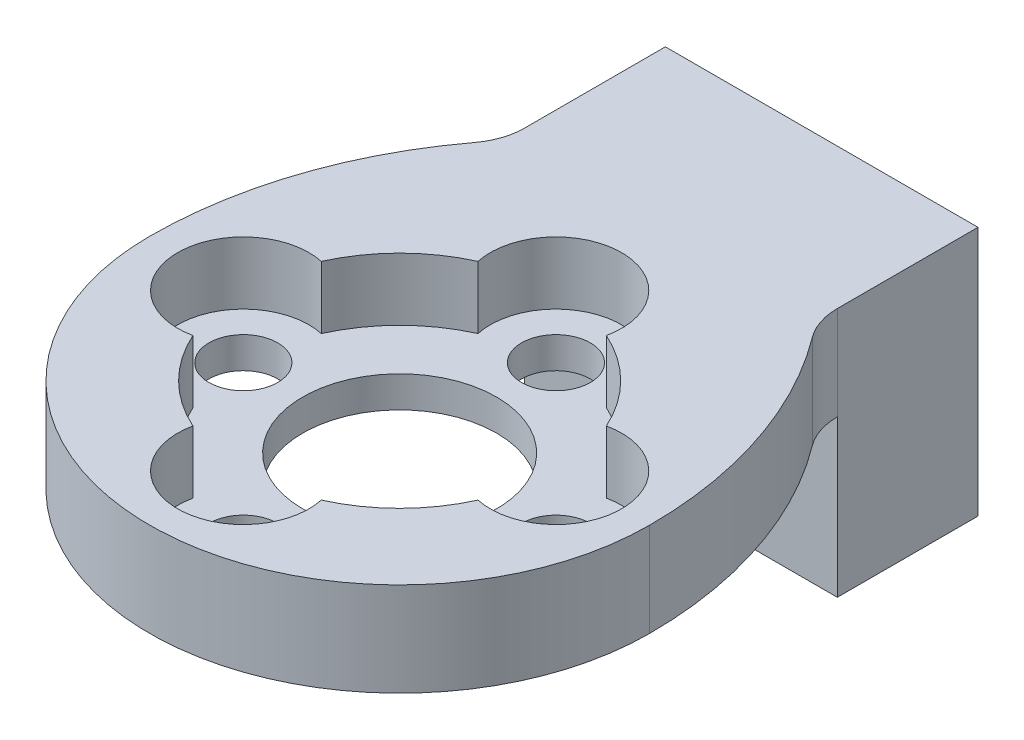
from build123d import *

# Parameters (mm, degrees)
BOSS_EXTRUDE1_DEPTH            = 3
SKETCH2_W                      = 10
SKETCH2_H                      = 4.5
BOSS_EXTRUDE2_DEPTH            = 5
CUT_EXTRUDE1_DEPTH             = 2
F_2_2_2_2_DIAMETER_HOLE1_D     = 2.2
F_2_2_2_2_DIAMETER_HOLE1_DEPTH = 6.000025
F_6_2_6_2_DIAMETER_HOLE1_D     = 6.2
F_6_2_6_2_DIAMETER_HOLE1_DEPTH = 3
F_2_2_2_2_DIAMETER_HOLE2_D     = 2.2
F_2_2_2_2_DIAMETER_HOLE2_DEPTH = 3
F_2_5_2_5_DIAMETER_HOLE1_D     = 2.5
F_2_5_2_5_DIAMETER_HOLE1_DEPTH = 21.5
F_1_6_1_6_DIAMETER_HOLE1_D     = 1.6
F_1_6_1_6_DIAMETER_HOLE1_DEPTH = 4
F_1_6_1_6_DIAMETER_HOLE1_TIP   = 0.480688495
FILLET1_R                      = 2


with BuildPart() as part:
    # Sketch1 → Boss-Extrude1 (new body)
    with BuildSketch(Plane(origin=(0, 3, 0), x_dir=(1, 0, 0), z_dir=(0, 1, 0))):
        with BuildLine():
            Line((5.000000003, -5.193376137), (5.000000003, 0))
            Line((5.000000003, 0), (-4.999999997, 0))
            Line((-4.999999997, 0), (-4.999999997, -5.193376137))
            ThreePointArc((-4.999999997, -5.193376137), (-7.227019257, -9.084119567), (-7.999999997, -13.5))
            ThreePointArc((-7.999999997, -13.5), (3e-09, -21.5), (8.000000003, -13.5))
            ThreePointArc((8.000000003, -13.5), (7.227019264, -9.084119567), (5.000000003, -5.193376137))
        make_face()
    extrude(amount=-BOSS_EXTRUDE1_DEPTH)

    # Sketch2 → Boss-Extrude2 (add)
    with BuildSketch(Plane.XZ):
        with Locations((0, 2.25)):
            Rectangle(SKETCH2_W, SKETCH2_H)
    extrude(amount=BOSS_EXTRUDE2_DEPTH)

    # Sketch3 → Cut-Extrude1 (cut)
    with BuildSketch(Plane(origin=(0, 3, 0), x_dir=(-1, 0, 0), z_dir=(0, 1, 0))):
        with BuildLine():
            ThreePointArc((-2.053172912, 18.058999999), (-3.535533906, 17.035533905), (-4.559, 15.55317291))
            ThreePointArc((-4.559, 15.55317291), (-7.1, 13.5), (-4.559, 11.44682709))
            ThreePointArc((-4.559, 11.44682709), (-3.535533906, 9.964466094), (-2.053172911, 8.941))
            ThreePointArc((-2.053172911, 8.941), (0, 6.4), (2.05317291, 8.941))
            ThreePointArc((2.05317291, 8.941), (3.535533906, 9.964466094), (4.559, 11.44682709))
            ThreePointArc((4.559, 11.44682709), (7.1, 13.5), (4.559, 15.55317291))
            ThreePointArc((4.559, 15.55317291), (3.535533906, 17.035533906), (2.05317291, 18.059))
            ThreePointArc((2.05317291, 18.059), (-1e-09, 20.6), (-2.053172912, 18.058999999))
        make_face()
    extrude(amount=-CUT_EXTRUDE1_DEPTH, mode=Mode.SUBTRACT)

    # Ø2.2 (2.2) Diameter Hole1
    with Locations(Plane(origin=(0, 1, 0), x_dir=(1, 0, 0), z_dir=(0, 1, 0))):
        with Locations((-5, -13.5)):
            Hole(F_2_2_2_2_DIAMETER_HOLE1_D / 2, depth=F_2_2_2_2_DIAMETER_HOLE1_DEPTH)

    # Ø6.2 (6.2) Diameter Hole1
    with Locations(Plane(origin=(0, 0, 0), x_dir=(-1, 0, 0), z_dir=(0, -1, 0))):
        with Locations((0, -13.5)):
            Hole(F_6_2_6_2_DIAMETER_HOLE1_D / 2, depth=F_6_2_6_2_DIAMETER_HOLE1_DEPTH)

    # Ø2.2 (2.2) Diameter Hole2
    with Locations(Plane(origin=(0, 0, 0), x_dir=(-1, 0, 0), z_dir=(0, -1, 0))):
        with Locations((0, -8.5), (-5, -13.5), (0, -18.5)):
            Hole(F_2_2_2_2_DIAMETER_HOLE2_D / 2, depth=F_2_2_2_2_DIAMETER_HOLE2_DEPTH)

    # Ø2.5 (2.5) Diameter Hole1
    with Locations(Plane(origin=(0, 0, 0), x_dir=(-1, 0, 0), z_dir=(0, 0, -1))):
        with Locations((-1.5, -2)):
            Hole(F_2_5_2_5_DIAMETER_HOLE1_D / 2, depth=F_2_5_2_5_DIAMETER_HOLE1_DEPTH)

    # Ø1.6 (1.6) Diameter Hole1
    with Locations(Plane(origin=(0, 0, 0), x_dir=(-1, 0, 0), z_dir=(0, 0, -1))):
        with Locations((3, 1)):
            Hole(F_1_6_1_6_DIAMETER_HOLE1_D / 2, depth=F_1_6_1_6_DIAMETER_HOLE1_DEPTH)
            with Locations((0, 0, -(F_1_6_1_6_DIAMETER_HOLE1_DEPTH + F_1_6_1_6_DIAMETER_HOLE1_TIP / 2))):  # 118° drill point
                Cone(0, F_1_6_1_6_DIAMETER_HOLE1_D / 2, F_1_6_1_6_DIAMETER_HOLE1_TIP, mode=Mode.SUBTRACT)

    # Fillet1
    fillet1_edges = [part.edges().sort_by_distance(p)[0] for p in [
        (5.000000003, 1.5, 5.193376137),
        (-4.999999997, 1.5, 5.193376137),
    ]]
    fillet(fillet1_edges, radius=FILLET1_R)


solid = part.part
